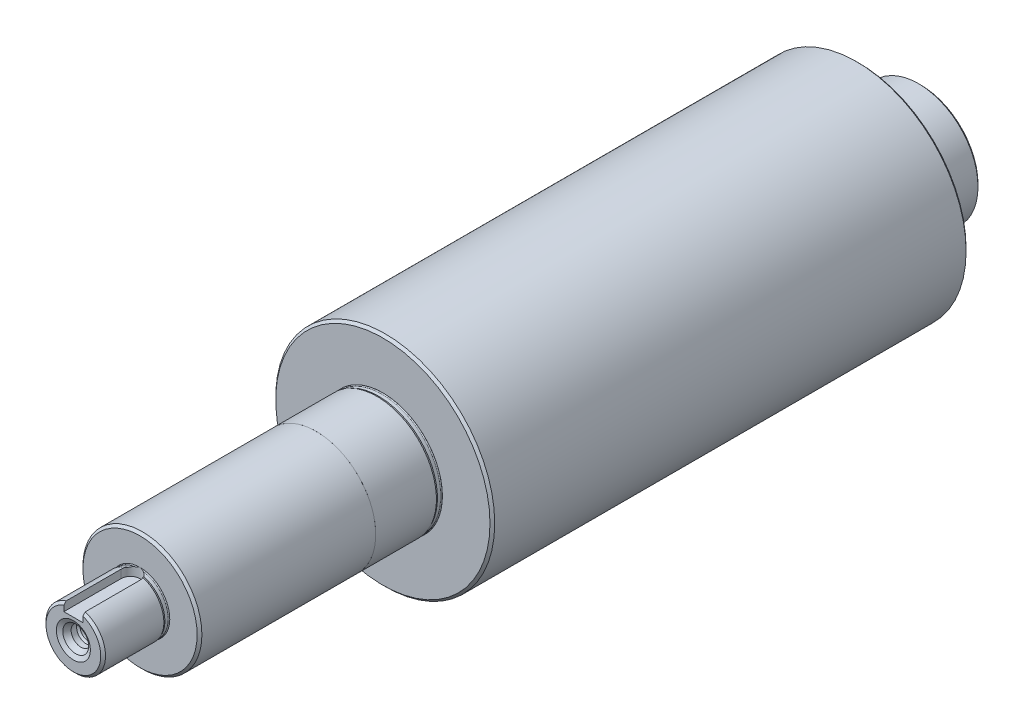
from build123d import *

# Parameters (mm, degrees)
SKICA1_R                 = 25
P_IDAT_VYSUNUT_M1_DEPTH  = 26
SKICA2_R                 = 46
P_IDAT_VYSUNUT_M2_DEPTH  = 200
SKICA3_R                 = 25
P_IDAT_VYSUNUT_M3_DEPTH  = 28
SKICA4_R                 = 24.99
P_IDAT_VYSUNUT_M4_DEPTH  = 74
SKICA5_R                 = 12.5
P_IDAT_VYSUNUT_M5_DEPTH  = 28
ZKOSEN_1_SIZE            = 1
ODEBRAT_START            = 12.5
ODEBRAT_VYSUNUT_M2_DEPTH = 4.1
M8_Z_VIT1_D              = 6.8
M8_Z_VIT1_DEPTH          = 25
M8_Z_VIT1_TIP            = 2.042926105


with BuildPart() as part:
    # Skica1 → Přidat vysunutím1 (new body)
    with BuildSketch(Plane.XY):
        with Locations(Location((0, 0, 0), (0, 0, 180))):
            Circle(SKICA1_R)
    extrude(amount=P_IDAT_VYSUNUT_M1_DEPTH)

    # Skica2 → Přidat vysunutím2 (add)
    with BuildSketch(Plane.XY.offset(26)):
        Circle(SKICA2_R)
    extrude(amount=P_IDAT_VYSUNUT_M2_DEPTH)

    # Skica3 → Přidat vysunutím3 (add)
    with BuildSketch(Plane.XY.offset(226)):
        with Locations(Location((0, 0, 0), (0, 0, 180))):
            Circle(SKICA3_R)
    extrude(amount=P_IDAT_VYSUNUT_M3_DEPTH)

    # Skica4 → Přidat vysunutím4 (add)
    with BuildSketch(Plane.XY.offset(254)):
        Circle(SKICA4_R)
    extrude(amount=P_IDAT_VYSUNUT_M4_DEPTH)

    # Skica5 → Přidat vysunutím5 (add)
    with BuildSketch(Plane.XY.offset(328)):
        Circle(SKICA5_R)
    extrude(amount=P_IDAT_VYSUNUT_M5_DEPTH)

    # Zkosení1
    zkosen_1_edges = [part.edges().sort_by_distance(p)[0] for p in [
        (-24.99, 0, 328),
        (25, 0, 0),
        (-12.5, 0, 356),
        (-46, 0, 26),
        (-46, 0, 226),
    ]]
    chamfer(zkosen_1_edges, length=ZKOSEN_1_SIZE)

    # Skica15 → Odebrat rotací12 (revolve, cut)
    with BuildSketch(Plane(origin=(0, 0, 0), x_dir=(0, 0, -1), z_dir=(1, 0, 0)), mode=Mode.PRIVATE) as odebrat_rotac_12_sk:
        with BuildLine():
            Line((-226.4, 24.7), (-227.775735931, 24.7))
            Line((-227.775735931, 24.7), (-228.5, 25))
            Line((-228.5, 25), (-226.012701665, 25))
            ThreePointArc((-226.012701665, 25), (-226.155051026, 24.783772234), (-226.4, 24.7))
        make_face()
        with BuildLine():
            Line((-23.512701665, 25), (-24.28634316, 24.873361621))
            Line((-24.28634316, 24.873361621), (-25.662079091, 24.873361621))
            ThreePointArc((-25.662079091, 24.873361621), (-25.846132218, 24.896407636), (-26, 25))
            Line((-26, 25), (-23.512701665, 25))
        make_face()
        with BuildLine():
            Line((-328, 12.5), (-330.487298335, 12.5))
            Line((-330.487298335, 12.5), (-329.763034266, 12.2))
            Line((-329.763034266, 12.2), (-328.387298335, 12.2))
            ThreePointArc((-328.387298335, 12.2), (-328.14234936, 12.283772234), (-328, 12.5))
        make_face()
    revolve(odebrat_rotac_12_sk.sketch.rotate(Axis((0, 0, 400.442816929), (0, 0, 1)), 90), axis=Axis((0, 0, 400.442816929), (0, 0, 1)), mode=Mode.SUBTRACT)

    # Skica16 → Odebrat vysunutím2 (cut)
    with BuildSketch(Plane(origin=(0, 0, 0), x_dir=(1, 0, 0), z_dir=(0, 1, 0)).offset(ODEBRAT_START)):
        with BuildLine():
            Line((-4, -356), (-4, -332.00000019))
            ThreePointArc((-4, -332.00000019), (0, -328), (4, -332.00000019))
            Line((4, -332.00000019), (4, -356))
            Line((4, -356), (-4, -356))
        make_face()
    extrude(amount=-ODEBRAT_VYSUNUT_M2_DEPTH, mode=Mode.SUBTRACT)

    # Skica17 → Odebrat rotací14 (revolve, cut)
    with BuildSketch(Plane(origin=(0, 0, 0), x_dir=(1, 0, 0), z_dir=(0, 1, 0))):
        Polygon((0, -356), (-7.15, -356), (-5.417949192, -355), (-4.1477786, -352.8), (-4.1477786, -350.5), (-3.4, -349.7522214), (0, -349.7522214), align=None)
    revolve(axis=Axis((0, 0, 356), (0, 0, 1)), mode=Mode.SUBTRACT)

    # M8 závit1
    with Locations(Plane.XY.offset(349.7522214)):
        with Locations((0, 0)):
            Hole(M8_Z_VIT1_D / 2, depth=M8_Z_VIT1_DEPTH)
            with Locations((0, 0, -(M8_Z_VIT1_DEPTH + M8_Z_VIT1_TIP / 2))):  # 118° drill point
                Cone(0, M8_Z_VIT1_D / 2, M8_Z_VIT1_TIP, mode=Mode.SUBTRACT)


solid = part.part
